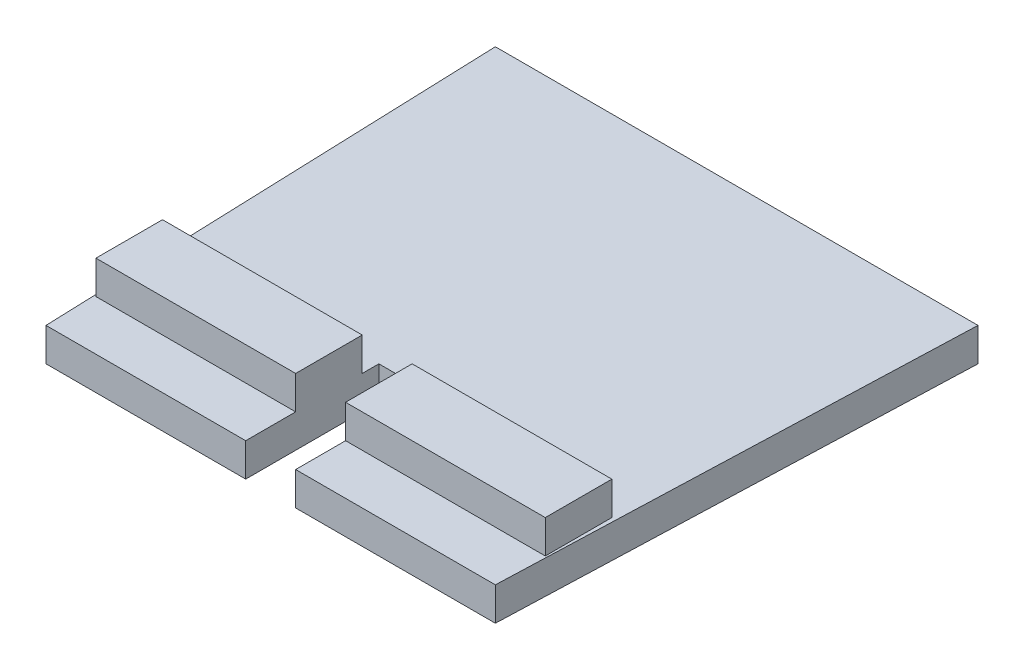
from build123d import *

# Parameters (mm, degrees)
BOSS_EXTRUDE2_DEPTH     = 20
SKETCH1_7_W             = 270
SKETCH1_7_H             = 40
BOSS_EXTRUDE3_DEPTH     = 40
SKETCH1_9_W             = 30
SKETCH1_9_H             = 80
CUT_EXTRUDE4_DEPTH      = 41
CUT_EXTRUDE4_DEPTH_BACK = 1


with BuildPart() as part:
    # Sketch1 → Boss-Extrude2 (new body)
    with BuildSketch(Plane(origin=(0, 0, 0), x_dir=(1, 0, 0), z_dir=(0, 1, 0))):
        Polygon((0, 0), (270, 0), (280, 280), (-10, 280), align=None)
    extrude(amount=BOSS_EXTRUDE2_DEPTH)

    # Sketch1_7 → Boss-Extrude3 (add)
    with BuildSketch(Plane(origin=(0, 0, 0), x_dir=(1, 0, 0), z_dir=(0, 1, 0))):
        with Locations((135, 50)):
            Rectangle(SKETCH1_7_W, SKETCH1_7_H)
    extrude(amount=BOSS_EXTRUDE3_DEPTH)

    # Sketch1_9 → Cut-Extrude4 (cut, two sides)
    with BuildSketch(Plane(origin=(0, 0, 0), x_dir=(1, 0, 0), z_dir=(0, 1, 0))) as cut_extrude4_sk:
        with Locations((135, 40)):
            Rectangle(SKETCH1_9_W, SKETCH1_9_H)
    extrude(amount=CUT_EXTRUDE4_DEPTH, mode=Mode.SUBTRACT)
    extrude(cut_extrude4_sk.sketch, amount=-CUT_EXTRUDE4_DEPTH_BACK, mode=Mode.SUBTRACT)


solid = part.part
